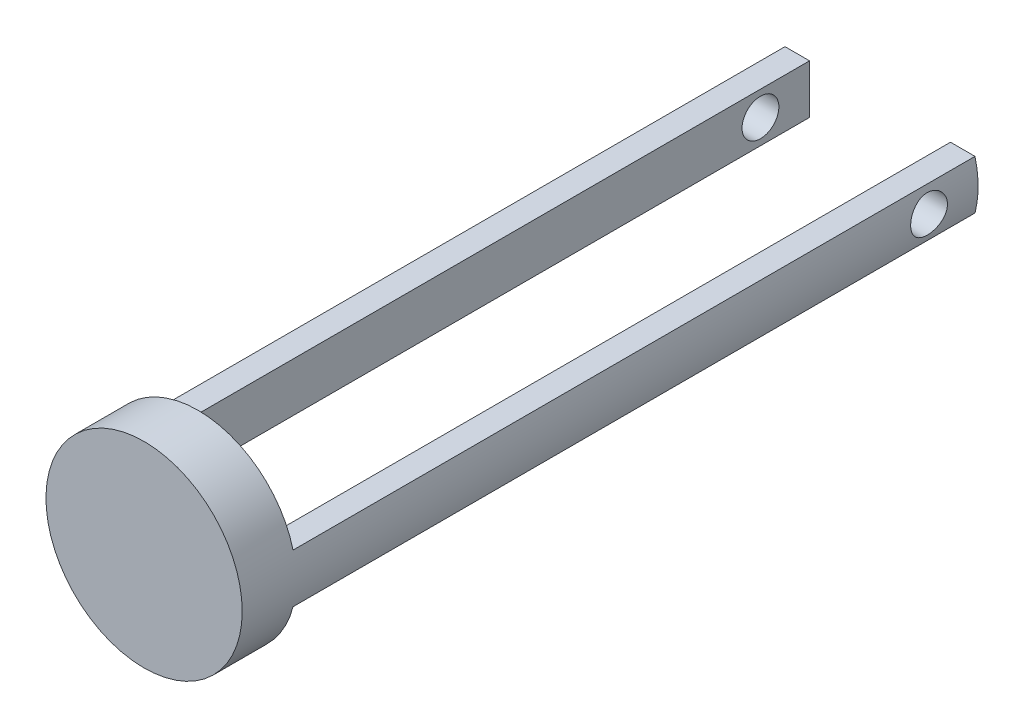
from build123d import *

# Parameters (mm, degrees)
SKETCH1_R               = 50.8
BOSS_EXTRUDE1_DEPTH     = 27.94
BOSS_EXTRUDE2_DEPTH     = 353.06
SKETCH3_R               = 9.525
CUT_EXTRUDE1_DEPTH      = 51.8
CUT_EXTRUDE1_DEPTH_BACK = 51.8


with BuildPart() as part:
    # Sketch1 → Boss-Extrude1 (new body)
    with BuildSketch(Plane.XY):
        Circle(SKETCH1_R)
    extrude(amount=BOSS_EXTRUDE1_DEPTH)

    # Sketch2 → Boss-Extrude2 (add)
    with BuildSketch(Plane(origin=(0, 0, 0), x_dir=(-1, 0, 0), z_dir=(0, 0, -1))):
        with BuildLine():
            Line((-49.186888, 12.7), (-36.486888, 12.7))
            Line((-36.486888, 12.7), (-36.486888, -12.7))
            Line((-36.486888, -12.7), (-49.186888, -12.7))
            ThreePointArc((-49.186888, -12.7), (-50.8, 0), (-49.186888, 12.7))
        make_face()
        with BuildLine():
            Line((49.186888, 12.7), (36.486888, 12.7))
            Line((36.486888, 12.7), (36.486888, -12.7))
            Line((36.486888, -12.7), (49.186888, -12.7))
            ThreePointArc((49.186888, -12.7), (50.8, 0), (49.186888, 12.7))
        make_face()
    extrude(amount=BOSS_EXTRUDE2_DEPTH)

    # Sketch3 → Cut-Extrude1 (cut, two sides)
    with BuildSketch(Plane(origin=(0, 0, 0), x_dir=(0, 0, -1), z_dir=(1, 0, 0))) as cut_extrude1_sk:
        with Locations((327.66, 0)):
            Circle(SKETCH3_R)
    extrude(amount=CUT_EXTRUDE1_DEPTH, mode=Mode.SUBTRACT)
    extrude(cut_extrude1_sk.sketch, amount=-CUT_EXTRUDE1_DEPTH_BACK, mode=Mode.SUBTRACT)


solid = part.part
